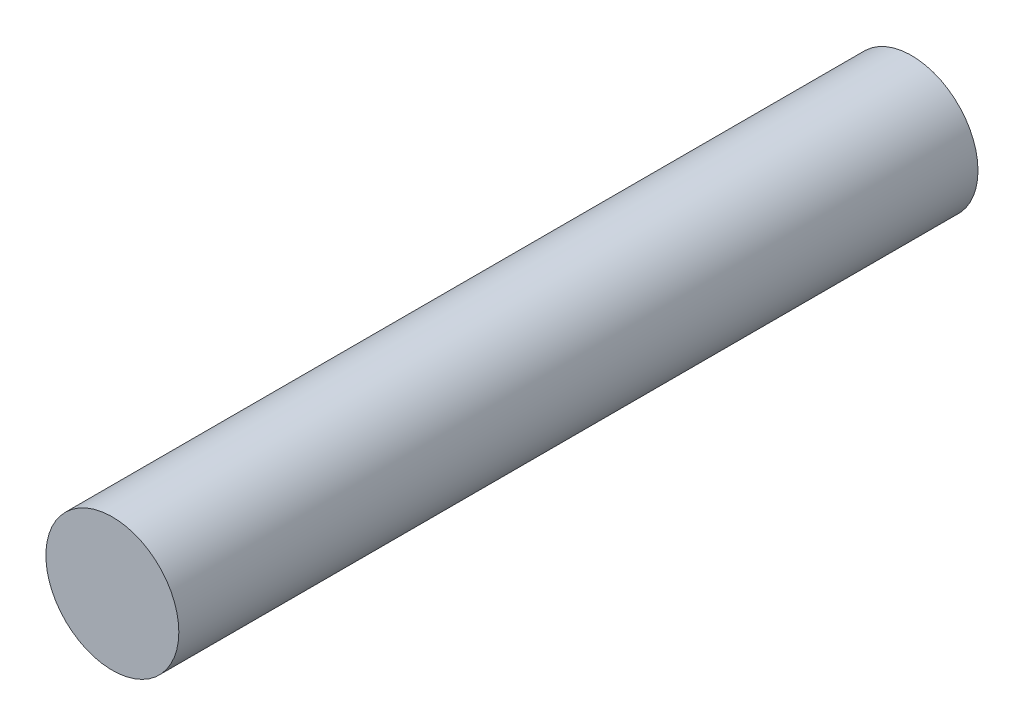
from build123d import *

# Parameters (mm, degrees)
SKETCH1_R           = 12.47648
BOSS_EXTRUDE1_DEPTH = 150


with BuildPart() as part:
    # Sketch1 → Boss-Extrude1 (new body)
    with BuildSketch(Plane.XY):
        Circle(SKETCH1_R)
    extrude(amount=BOSS_EXTRUDE1_DEPTH)


solid = part.part
